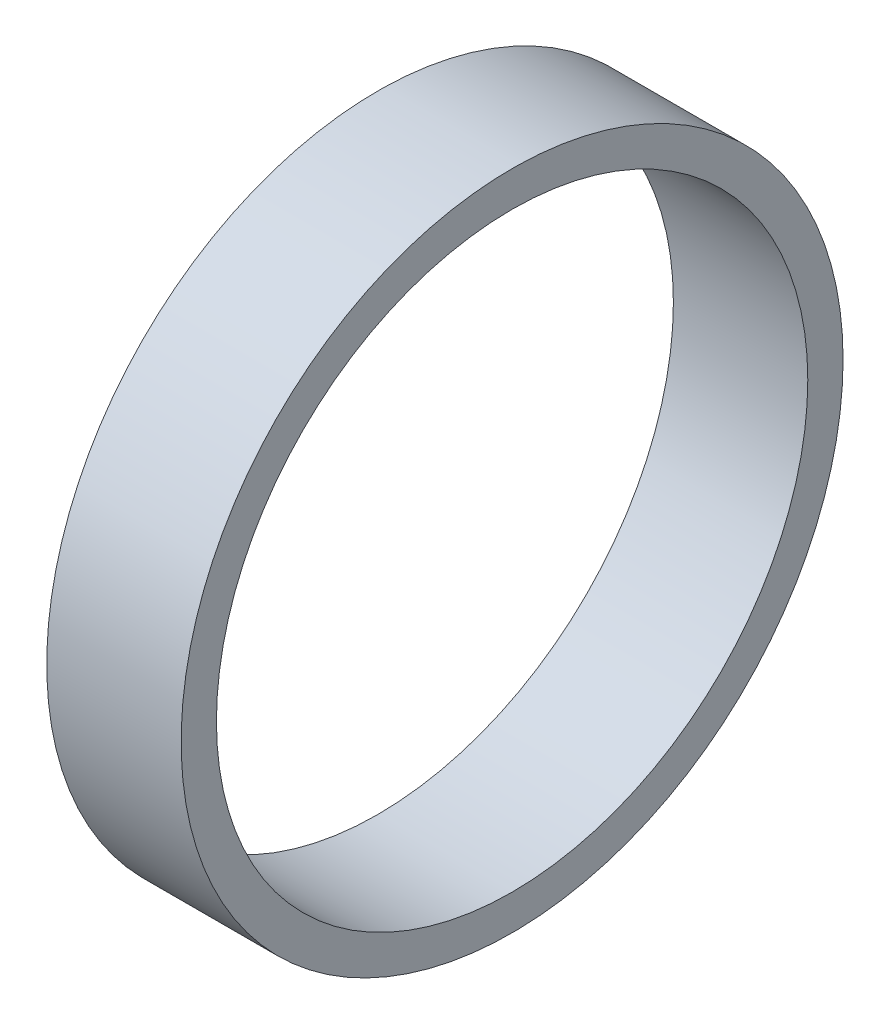
from build123d import *

# Parameters (mm, degrees)
SKETCH_1_R      = 4.925
SKETCH_1_R_2    = 4.4
EXTRUDE_1_DEPTH = 2


with BuildPart() as part:
    # 草图1 → 凸台-拉伸1 (new body)
    with BuildSketch(Plane(origin=(0, 0, 0), x_dir=(0, 0, -1), z_dir=(1, 0, 0))):
        Circle(SKETCH_1_R)
        Circle(SKETCH_1_R_2, mode=Mode.SUBTRACT)
    extrude(amount=EXTRUDE_1_DEPTH)


solid = part.part
